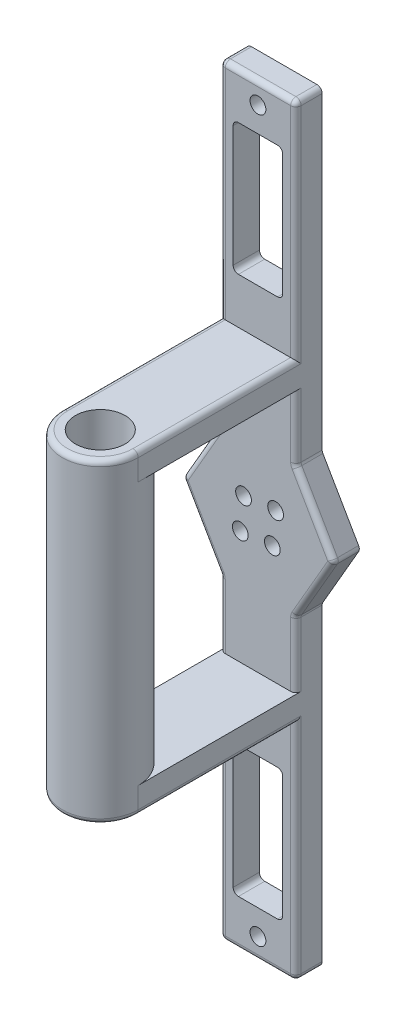
from build123d import *

# Parameters (mm, degrees)
BOSS_EXTRUDE2_DEPTH      = 10
SKETCH2_R                = 3
CUT_EXTRUDE1_DEPTH       = 5
CUT_EXTRUDE2_REACH       = 40.514
SKETCH3_R                = 1.5
SKETCH4_W                = 28.86751346
SKETCH4_H                = 120
SKETCH4_R                = 1.5
BOSS_EXTRUDE4_DEPTH      = 10
SKETCH5_R                = 3
CUT_EXTRUDE3_DEPTH       = 5
SKETCH6_W                = 4
SKETCH6_H                = 2
SKETCH6_W_2              = 2
SKETCH6_H_2              = 4
CUT_EXTRUDE4_DEPTH       = 4
SKETCH7_R                = 14.43375673
BOSS_EXTRUDE5_DEPTH      = 60
SKETCH8_R                = 9.43375673
CUT_EXTRUDE6_DEPTH       = 120
BOSS_EXTRUDE6_REACH      = 167.526
BOSS_EXTRUDE6_END_RADIUS = 14.43375673
SKETCH11_W               = 28.86751346
SKETCH11_H               = 10
CUT_EXTRUDE7_REACH       = 167.526
SKETCH13_W               = 18.86751346
SKETCH13_H               = 50
FILLET3_R                = 2
FILLET4_R                = 2


with BuildPart() as part:
    # Sketch1 → Boss-Extrude2 (new body)
    with BuildSketch(Plane.XY):
        Polygon((14.43375673, 25), (-14.43375673, 25), (-28.867513459, 0), (-14.43375673, -25), (14.43375673, -25), (28.867513459, 0), align=None)
    extrude(amount=BOSS_EXTRUDE2_DEPTH)

    # Sketch2 → Cut-Extrude1 (cut)
    with BuildSketch(Plane.XY.offset(10)):
        with Locations((-5.480077554, 5.480077554)):
            Circle(SKETCH2_R)
        with Locations((6.717514421, 6.717514421)):
            Circle(SKETCH2_R)
        with Locations((5.480077554, -5.480077554)):
            Circle(SKETCH2_R)
        with Locations((-6.717514421, -6.717514421)):
            Circle(SKETCH2_R)
    extrude(amount=-CUT_EXTRUDE1_DEPTH, mode=Mode.SUBTRACT)

    # Sketch3 → Cut-Extrude2 (cut, up to next)
    with BuildSketch(Plane.XY.offset(5), mode=Mode.PRIVATE) as cut_extrude2_sk1:
        with Locations((-5.480077554, 5.480077554)):
            Circle(SKETCH3_R)
    cut_extrude2_tool1 = extrude(cut_extrude2_sk1.sketch, amount=-CUT_EXTRUDE2_REACH, mode=Mode.PRIVATE) & part.part
    # Sketch3 → Cut-Extrude2 (cut, up to next)
    with BuildSketch(Plane.XY.offset(5), mode=Mode.PRIVATE) as cut_extrude2_sk2:
        with Locations((6.717514421, 6.717514421)):
            Circle(SKETCH3_R)
    cut_extrude2_tool2 = extrude(cut_extrude2_sk2.sketch, amount=-CUT_EXTRUDE2_REACH, mode=Mode.PRIVATE) & part.part
    # Sketch3 → Cut-Extrude2 (cut, up to next)
    with BuildSketch(Plane.XY.offset(5), mode=Mode.PRIVATE) as cut_extrude2_sk3:
        with Locations((5.480077554, -5.480077554)):
            Circle(SKETCH3_R)
    cut_extrude2_tool3 = extrude(cut_extrude2_sk3.sketch, amount=-CUT_EXTRUDE2_REACH, mode=Mode.PRIVATE) & part.part
    # Sketch3 → Cut-Extrude2 (cut, up to next)
    with BuildSketch(Plane.XY.offset(5), mode=Mode.PRIVATE) as cut_extrude2_sk4:
        with Locations((-6.717514421, -6.717514421)):
            Circle(SKETCH3_R)
    cut_extrude2_tool4 = extrude(cut_extrude2_sk4.sketch, amount=-CUT_EXTRUDE2_REACH, mode=Mode.PRIVATE) & part.part
    add(cut_extrude2_tool1.solids().sort_by_distance((-5.480078, 5.480078, 5))[0], mode=Mode.SUBTRACT)
    add(cut_extrude2_tool2.solids().sort_by_distance((6.717514, 6.717514, 5))[0], mode=Mode.SUBTRACT)
    add(cut_extrude2_tool3.solids().sort_by_distance((5.480078, -5.480078, 5))[0], mode=Mode.SUBTRACT)
    add(cut_extrude2_tool4.solids().sort_by_distance((-6.717514, -6.717514, 5))[0], mode=Mode.SUBTRACT)

    # Sketch4 → Boss-Extrude4 (add)
    with BuildSketch(Plane(origin=(0, 0, 0), x_dir=(-1, 0, 0), z_dir=(0, 0, -1))):
        with Locations((0, 85)):
            Rectangle(SKETCH4_W, SKETCH4_H)
        with Locations((0, 137)):
            Circle(SKETCH4_R, mode=Mode.SUBTRACT)
        with Locations((0, -85)):
            Rectangle(SKETCH4_W, SKETCH4_H)
        with Locations(Location((0, -137, 0), (0, 0, 180))):
            Circle(SKETCH4_R, mode=Mode.SUBTRACT)
    extrude(amount=-BOSS_EXTRUDE4_DEPTH)

    # Sketch5 → Cut-Extrude3 (cut)
    with BuildSketch(Plane.XY.offset(10)):
        with Locations((0, 137)):
            Circle(SKETCH5_R)
        with Locations((0, -137)):
            Circle(SKETCH5_R)
    extrude(amount=-CUT_EXTRUDE3_DEPTH, mode=Mode.SUBTRACT)

    # Sketch6 → Cut-Extrude4 (cut)
    with BuildSketch(Plane(origin=(0, 0, 0), x_dir=(-1, 0, 0), z_dir=(0, 0, -1))):
        with Locations((5, 137)):
            Rectangle(SKETCH6_W, SKETCH6_H)
        with Locations((0, 142)):
            Rectangle(SKETCH6_W_2, SKETCH6_H_2)
        with Locations((0, 132)):
            Rectangle(SKETCH6_W_2, SKETCH6_H_2)
        with Locations((-5, 137)):
            Rectangle(SKETCH6_W, SKETCH6_H)
        with Locations((0, -132)):
            Rectangle(SKETCH6_W_2, SKETCH6_H_2)
        with Locations((5, -137)):
            Rectangle(SKETCH6_W, SKETCH6_H)
        with Locations((-5, -137)):
            Rectangle(SKETCH6_W, SKETCH6_H)
        with Locations((0, -142)):
            Rectangle(SKETCH6_W_2, SKETCH6_H_2)
    extrude(amount=-CUT_EXTRUDE4_DEPTH, mode=Mode.SUBTRACT)



with BuildPart() as body_2:
    # Sketch7 → Boss-Extrude5 (new, symmetric)
    with BuildSketch(Plane(origin=(0, 0, 0), x_dir=(1, 0, 0), z_dir=(0, 1, 0))):
        with Locations(Location((0, -70, 0), (0, 0, 270))):
            Circle(SKETCH7_R)
    extrude(amount=BOSS_EXTRUDE5_DEPTH, both=True)

    # Sketch8 → Cut-Extrude6 (cut)
    with BuildSketch(Plane.XZ.offset(60)):
        with Locations(Location((0, 70, 0), (0, 0, 270))):
            Circle(SKETCH8_R)
    extrude(amount=-CUT_EXTRUDE6_DEPTH, mode=Mode.SUBTRACT)


with BuildPart() as part_1:
    add(part.part)

    add(body_2.part)  # Boss-Extrude6 merges body 2
    # Boss-Extrude6: up to this cylinder (the profile starts outside it)
    boss_extrude6_end = Plane(origin=(0, 55, 70), z_dir=(0, -1, 0)) * Cylinder(BOSS_EXTRUDE6_END_RADIUS, 364.919513459, mode=Mode.PRIVATE)
    # Sketch11 → Boss-Extrude6 (add, up to the surface)
    with BuildSketch(Plane.XY.offset(10), mode=Mode.PRIVATE) as boss_extrude6_sk1:
        with Locations((0, 55)):
            Rectangle(SKETCH11_W, SKETCH11_H)
    boss_extrude6_tool1 = extrude(boss_extrude6_sk1.sketch, amount=BOSS_EXTRUDE6_REACH, mode=Mode.PRIVATE) - boss_extrude6_end
    boss_extrude6 = boss_extrude6_tool1.solids().sort_by_distance((0, 55, 10))[0]
    add(boss_extrude6)

    # Mirror1: Boss-Extrude6 across plane
    add(boss_extrude6.mirror(Plane.ZX))

    # Sketch13 → Cut-Extrude7 (cut, up to next)
    with BuildSketch(Plane.XY.offset(10), mode=Mode.PRIVATE) as cut_extrude7_sk1:
        with Locations((0, 102.5)):
            Rectangle(SKETCH13_W, SKETCH13_H)
    cut_extrude7_tool1 = extrude(cut_extrude7_sk1.sketch, amount=-CUT_EXTRUDE7_REACH, mode=Mode.PRIVATE) & part_1.part
    # Sketch13 → Cut-Extrude7 (cut, up to next)
    with BuildSketch(Plane.XY.offset(10), mode=Mode.PRIVATE) as cut_extrude7_sk2:
        with Locations((0, -102.5)):
            Rectangle(SKETCH13_W, SKETCH13_H)
    cut_extrude7_tool2 = extrude(cut_extrude7_sk2.sketch, amount=-CUT_EXTRUDE7_REACH, mode=Mode.PRIVATE) & part_1.part
    add(cut_extrude7_tool1.solids().sort_by_distance((0, 102.5, 10))[0], mode=Mode.SUBTRACT)
    add(cut_extrude7_tool2.solids().sort_by_distance((0, -102.5, 10))[0], mode=Mode.SUBTRACT)

    # Fillet3
    fillet3_edges = [part_1.edges().sort_by_distance(p)[0] for p in [
        (28.867513459, 0, 5),
        (14.43375673, -25, 5),
        (-14.43375673, -25, 5),
        (-28.867513459, 0, 5),
        (-14.43375673, 25, 5),
        (14.43375673, 25, 5),
        (14.43375673, 60, 40),
        (-14.43375673, 60, 40),
        (10.206207262, 60, 80.206207262),
        (10.206207262, -60, 80.206207262),
        (-14.43375673, -60, 40),
        (14.43375673, -60, 40),
        (-9.43375673, 77.5, 5),
        (-9.43375673, 127.5, 5),
        (9.43375673, 127.5, 5),
        (9.43375673, 77.5, 5),
        (9.43375673, -77.5, 5),
        (9.43375673, -127.5, 5),
        (-9.43375673, -127.5, 5),
        (-9.43375673, -77.5, 5),
        (14.43375673, 145, 5),
        (-14.43375673, 145, 5),
        (14.43375673, -145, 5),
        (-14.43375673, -145, 5),
    ]]
    fillet(fillet3_edges, radius=FILLET3_R)

    # Fillet4
    fillet4_edges = [part_1.edges().sort_by_distance(p)[0] for p in [
        (14.43375673, 37.767949192, 10),
        (-14.43375673, 100.5, 10),
        (-14.43375673, -37.767949192, 10),
        (14.43375673, -100.5, 10),
        (-14.43375673, 37.767949192, 10),
        (14.43375673, 100.5, 10),
        (21.495934556, 12.767949192, 10),
        (0, 145, 10),
        (-21.495934556, 12.767949192, 10),
        (-21.495934556, -12.767949192, 10),
        (14.43375673, -37.767949192, 10),
        (21.495934556, -12.767949192, 10),
        (-14.43375673, -100.5, 10),
        (0, -145, 10),
        (14.501905077, 25.018260295, 10),
        (-14.501905077, 25.018260295, 10),
        (-14.501905077, -25.018260295, 10),
        (14.501905077, -25.018260295, 10),
        (13.847970292, 144.414213562, 10),
        (-13.847970292, 144.414213562, 10),
        (28.558112383, 0, 10),
        (-28.558112383, 0, 10),
        (13.847970292, -144.414213562, 10),
        (-13.847970292, -144.414213562, 10),
    ]]
    fillet(fillet4_edges, radius=FILLET4_R)


solid = part_1.part
